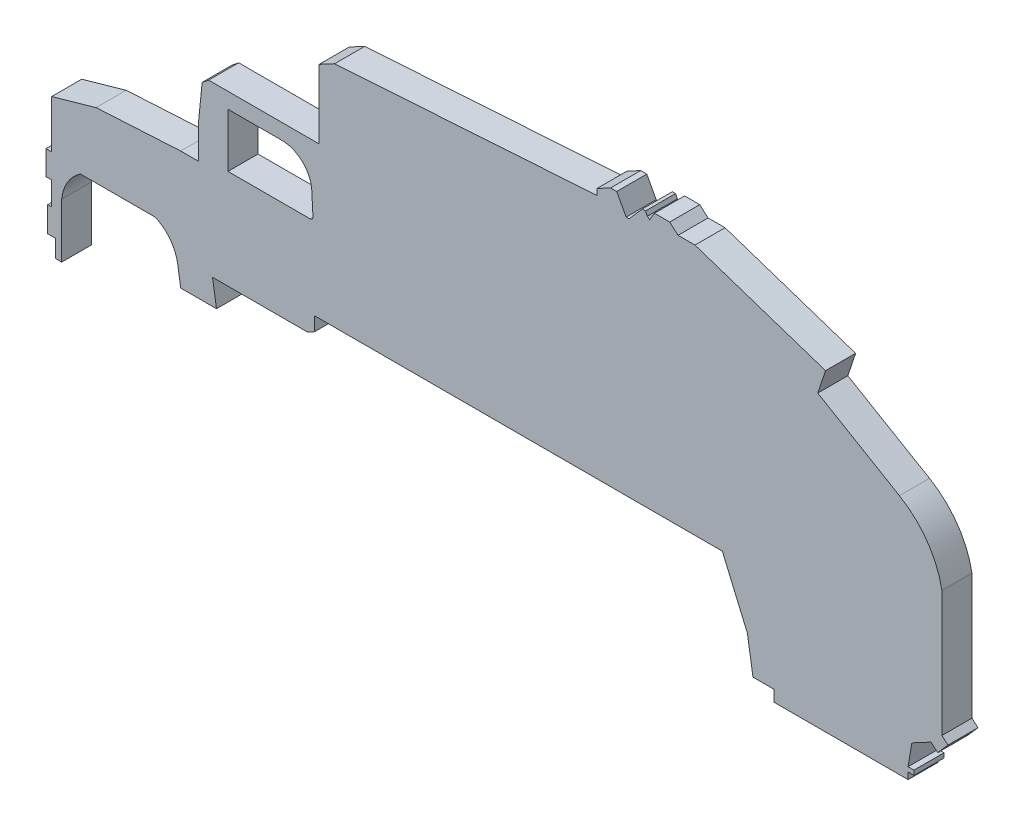
from build123d import *

# Parameters (mm, degrees)
BOSS_EXTRUDE1_DEPTH     = 2.54
CUT_EXTRUDE1_DEPTH      = 1
CUT_EXTRUDE1_DEPTH_BACK = 3.54


with BuildPart() as part:
    # Sketch1 → Boss-Extrude1 (new body)
    with BuildSketch(Plane.XY):
        with BuildLine():
            Line((5.391744354, 14.282870357), (5.391744354, 15.765239208))
            Line((5.391744354, 15.765239208), (4.741317205, 15.765239208))
            Line((4.741317205, 15.765239208), (4.741317205, 17.898035208))
            Line((4.741317205, 17.898035208), (5.066530779, 17.898035208))
            Line((5.066530779, 17.898035208), (5.066530779, 19.876846363))
            Line((5.066530779, 19.876846363), (4.595500514, 19.876846363))
            Line((4.595500514, 19.876846363), (4.595500514, 21.924330523))
            Line((4.595500514, 21.924330523), (5.066530779, 21.924330523))
            Line((5.066530779, 21.924330523), (5.066530779, 25.970641097))
            Line((5.066530779, 25.970641097), (8.827667811, 27.043705429))
            Line((8.827667811, 27.043705429), (15.977546955, 27.444115261))
            Line((15.977546955, 27.444115261), (17.49779469, 27.444115261))
            Line((17.49779469, 27.444115261), (17.49779469, 28.820580801))
            Line((17.49779469, 28.820580801), (17.49779469, 30.468511328))
            Line((17.49779469, 30.468511328), (17.783535415, 33.367238893))
            Line((17.783535415, 33.367238893), (18.335195157, 33.807947262))
            Line((18.335195157, 33.807947262), (27.675822425, 33.807947262))
            Line((27.675822425, 33.807947262), (27.675822425, 37.185188617))
            Line((27.675822425, 37.185188617), (27.675822425, 39.633723234))
            Line((27.675822425, 39.633723234), (28.980773711, 40.33269643))
            Line((28.980773711, 40.33269643), (51.141827963, 41.772000615))
            Line((51.141827963, 41.772000615), (51.141827963, 42.284268418))
            Line((51.141827963, 42.284268418), (52.296667979, 42.902837268))
            Line((52.296667979, 42.902837268), (52.814231672, 42.902837268))
            Line((52.814231672, 42.902837268), (53.607165269, 41.42246617))
            Line((53.607165269, 41.42246617), (53.853833977, 41.42246617))
            Line((53.853833977, 41.42246617), (54.968769782, 42.69106932))
            Line((54.968769782, 42.69106932), (55.239970384, 42.69106932))
            Line((55.239970384, 42.69106932), (55.403969099, 42.384891149))
            Line((55.403969099, 42.384891149), (55.598324769, 42.214078003))
            Line((55.598324769, 42.214078003), (56.003141291, 42.902837268))
            Line((56.003141291, 42.902837268), (57.289041594, 42.902837268))
            Line((57.289041594, 42.902837268), (57.992865427, 42.284268418))
            Line((57.992865427, 42.284268418), (59.425813052, 42.284268418))
            Line((59.425813052, 42.284268418), (70.454348226, 38.609355629))
            Line((70.454348226, 38.609355629), (69.798459804, 36.641012721))
            Line((69.798459804, 36.641012721), (76.698212964, 32.585700195))
            ThreePointArc((76.698212964, 32.585700195), (79.05388987, 30.406820911), (80.286409178, 27.444115261))
            Line((80.286409178, 27.444115261), (80.286409178, 21.776774623))
            Line((80.286409178, 21.776774623), (80.286409178, 16.831637208))
            Line((80.286409178, 16.831637208), (80.795500514, 16.384212686))
            Line((80.795500514, 16.384212686), (79.926633106, 15.395592601))
            Line((79.926633106, 15.395592601), (79.364194198, 15.889902643))
            Line((79.364194198, 15.889902643), (77.747695473, 15.024054782))
            Line((77.747695473, 15.024054782), (77.42948761, 13.121408956))
            Line((77.42948761, 13.121408956), (77.927923916, 13.121408956))
            Line((77.927923916, 13.121408956), (77.927923916, 12.734414773))
            Line((77.927923916, 12.734414773), (77.42948761, 12.734414773))
            Line((77.42948761, 12.734414773), (77.42948761, 12.173202104))
            Line((77.42948761, 12.173202104), (66.096875424, 12.173202104))
            Line((66.096875424, 12.173202104), (66.096875424, 13.121408956))
            Line((66.096875424, 13.121408956), (64.324624891, 13.121408956))
            Line((64.324624891, 13.121408956), (63.852024749, 16.101690785))
            Line((63.852024749, 16.101690785), (61.733497308, 21.0437176))
            Line((61.733497308, 21.0437176), (27.288990511, 21.0437176))
            Line((27.288990511, 21.0437176), (27.288990511, 19.876846363))
            Line((27.288990511, 19.876846363), (26.678188815, 19.54968165))
            Line((26.678188815, 19.54968165), (18.661272623, 19.54968165))
            Line((18.661272623, 19.54968165), (19.000020898, 17.4134882))
            Line((19.000020898, 17.4134882), (15.977546955, 17.4134882))
            Line((15.977546955, 17.4134882), (15.7129382, 19.082147588))
            ThreePointArc((15.7129382, 19.082147588), (15.077518105, 20.548119931), (13.813657174, 21.525611186))
            Line((13.813657174, 21.525611186), (7.510402991, 21.525611186))
            ThreePointArc((7.510402991, 21.525611186), (6.418297754, 20.38537823), (5.919290284, 18.887440786))
            Line((5.919290284, 18.887440786), (5.919290284, 14.282870357))
            Line((5.919290284, 14.282870357), (5.391744354, 14.282870357))
        make_face()
    extrude(amount=BOSS_EXTRUDE1_DEPTH)

    # Sketch2 → Cut-Extrude1 (cut, two sides)
    with BuildSketch(Plane.XY.offset(2.54)) as cut_extrude1_sk:
        with BuildLine():
            Line((19.967423309, 32.496521322), (24.512705526, 32.496521322))
            ThreePointArc((24.512705526, 32.496521322), (26.259153953, 31.800841764), (27.048934293, 30.094881867))
            Line((27.048934293, 30.094881867), (27.151503603, 28.214727135))
            ThreePointArc((27.151503603, 28.214727135), (27.08231277, 28.026246238), (26.897880726, 27.946891081))
            Line((26.897880726, 27.946891081), (19.967423309, 27.946891081))
            Line((19.967423309, 27.946891081), (19.967423309, 32.496521322))
        make_face()
    extrude(amount=CUT_EXTRUDE1_DEPTH, mode=Mode.SUBTRACT)
    extrude(cut_extrude1_sk.sketch, amount=-CUT_EXTRUDE1_DEPTH_BACK, mode=Mode.SUBTRACT)


solid = part.part
